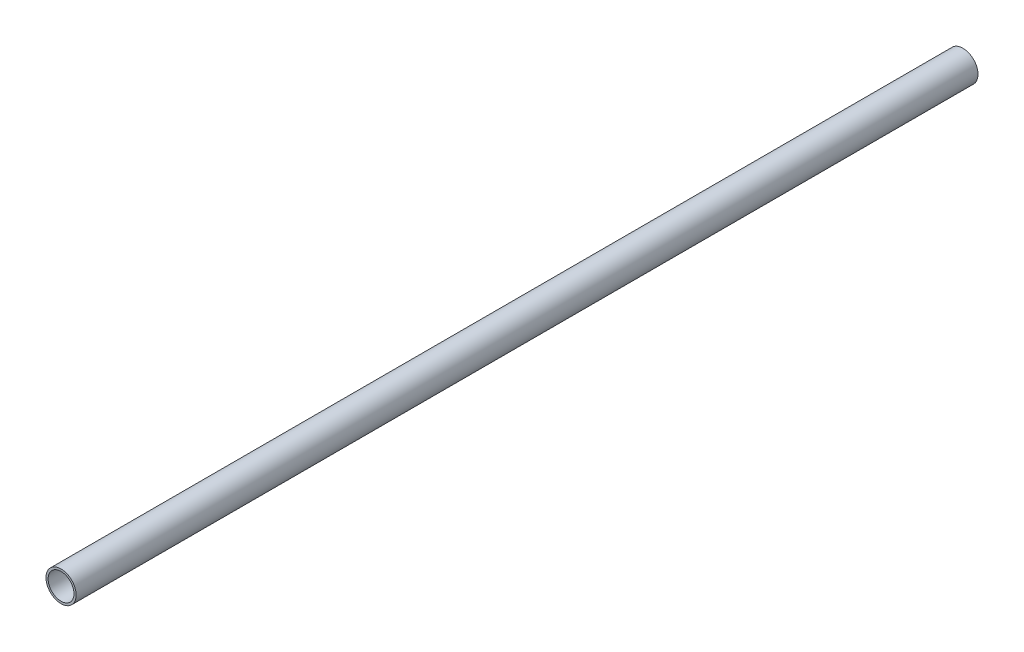
from build123d import *

# Parameters (mm, degrees)
SKETCH1_R           = 11.1125
SKETCH1_R_2         = 9.525
BOSS_EXTRUDE1_DEPTH = 332.359


with BuildPart() as part:
    # Sketch1 → Boss-Extrude1 (new body, symmetric)
    with BuildSketch(Plane.XY):
        Circle(SKETCH1_R)
        Circle(SKETCH1_R_2, mode=Mode.SUBTRACT)
    extrude(amount=BOSS_EXTRUDE1_DEPTH, both=True)


solid = part.part
